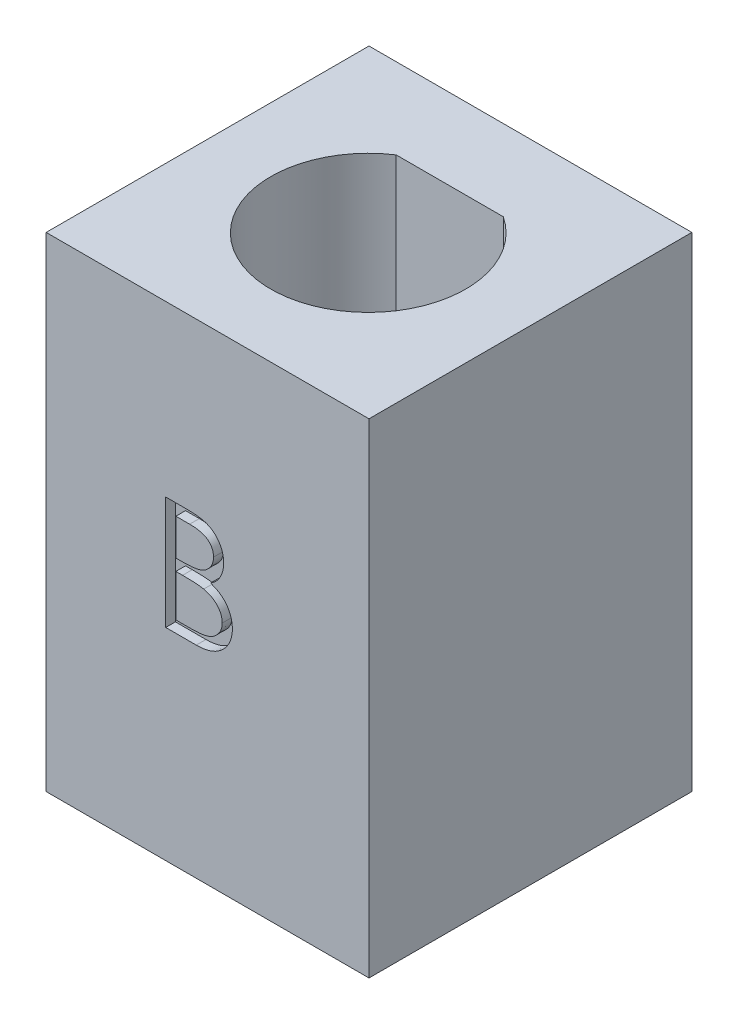
from build123d import *

# Parameters (mm, degrees)
SKETCH1_W           = 10
SKETCH1_H           = 10
BOSS_EXTRUDE1_DEPTH = 15
CUT_EXTRUDE1_DEPTH  = 0.3


with BuildPart() as part:
    # Sketch1 → Boss-Extrude1 (new body)
    with BuildSketch(Plane(origin=(0, 0, 0), x_dir=(1, 0, 0), z_dir=(0, 1, 0))):
        Rectangle(SKETCH1_W, SKETCH1_H)
        with BuildLine():
            Line((-1.658312395, 2.5), (1.658312395, 2.5))
            ThreePointArc((1.658312395, 2.5), (0, -3.043965134), (-1.658312395, 2.5))
        make_face(mode=Mode.SUBTRACT)
    extrude(amount=BOSS_EXTRUDE1_DEPTH)

    # Sketch2 → Cut-Extrude1 (cut)
    with BuildSketch(Plane.XY.offset(5)):
        with BuildLine():
            Line((-1.296362428, 9.754838654), (-0.6134698, 9.754838654))
            add(Edge.make_bspline(
                [(-0.6134698, 9.754838654), (-0.580041322, 9.754662904), (-0.515248611, 9.754322256), (-0.42102917, 9.749039125), (-0.332780359, 9.741835455), (-0.250476587, 9.730405362), (-0.174155884, 9.716613585), (-0.103588247, 9.699911769), (-0.038998075, 9.679885155), (0.038114662, 9.648038874), (0.126035323, 9.600715706), (0.221233715, 9.530787141), (0.302637955, 9.445254678), (0.372824272, 9.348772022), (0.428625391, 9.24263625), (0.468994689, 9.129377062), (0.494552564, 9.01045532), (0.497180998, 8.928812142), (0.498509367, 8.887550994)],
                knots=[0, 0, 0, 0, 0.00010027, 0.000194349, 0.000283026, 0.000365821, 0.000443519, 0.000515622, 0.000583254, 0.00064614, 0.000765662, 0.000881909, 0.000998927, 0.001118415, 0.001238844, 0.00135727, 0.001478274, 0.001601912, 0.001601912, 0.001601912, 0.001601912], degree=3))
            add(Edge.make_bspline(
                [(0.498509367, 8.887550994), (0.497416148, 8.848898438), (0.495267871, 8.772942521), (0.474725112, 8.661848412), (0.442564443, 8.556097193), (0.397859194, 8.456074808), (0.339757198, 8.364041195), (0.270898879, 8.279253929), (0.187822077, 8.205302872), (0.125578837, 8.163959969), (0.093962091, 8.142959648)],
                knots=[0, 0, 0, 0, 0.000115857, 0.00022767, 0.000337672, 0.000446877, 0.000555233, 0.000663318, 0.000773539, 0.000887324, 0.000887324, 0.000887324, 0.000887324], degree=3))
            add(Edge.make_bspline(
                [(0.093962091, 8.142959648), (0.133722519, 8.127694649), (0.209794066, 8.098488925), (0.314480078, 8.046853461), (0.404674923, 7.99069135), (0.481072069, 7.9293595), (0.546409724, 7.863250689), (0.603462666, 7.791395575), (0.65214404, 7.712856817), (0.693856964, 7.628453282), (0.72640572, 7.539046813), (0.750781624, 7.445476037), (0.764749073, 7.348076482), (0.766736714, 7.281791103), (0.767740136, 7.248328238)],
                knots=[0, 0, 0, 0, 0.000127722, 0.000244363, 0.000349599, 0.000445847, 0.000537565, 0.000627901, 0.000720503, 0.000814257, 0.000909859, 0.001005428, 0.001103887, 0.001204268, 0.001204268, 0.001204268, 0.001204268], degree=3))
            add(Edge.make_bspline(
                [(0.767740136, 7.248328238), (0.76676329, 7.214161366), (0.764841318, 7.146937088), (0.750661346, 7.048181953), (0.726652239, 6.953807006), (0.693581093, 6.863201824), (0.650418778, 6.776541689), (0.597890814, 6.693728425), (0.53525925, 6.615594095), (0.465196381, 6.541270471), (0.385934236, 6.474442684), (0.300418481, 6.414926977), (0.207572161, 6.365980915), (0.108920167, 6.324864894), (0.003355851, 6.293457695), (-0.108646757, 6.271485121), (-0.226991058, 6.256680084), (-0.308200809, 6.25546288), (-0.349848005, 6.254838654)],
                knots=[0, 0, 0, 0, 0.000102481, 0.000201635, 0.000298562, 0.000394165, 0.000490425, 0.000588455, 0.000687769, 0.000790423, 0.000894381, 0.000998232, 0.001102369, 0.001208616, 0.001318415, 0.001432129, 0.001550749, 0.00167562, 0.00167562, 0.00167562, 0.00167562], degree=3))
            Line((-0.349848005, 6.254838654), (-1.296362428, 6.254838654))
            Line((-1.296362428, 6.254838654), (-1.296362428, 9.754838654))
        make_face()
        with BuildLine():
            Line((-0.982259864, 9.395864295), (-0.982259864, 8.274069424))
            Line((-0.982259864, 8.274069424), (-0.771222204, 8.274069424))
            add(Edge.make_bspline(
                [(-0.771222204, 8.274069424), (-0.740373408, 8.274469347), (-0.680767249, 8.275242079), (-0.594447353, 8.277455596), (-0.514322334, 8.28365364), (-0.440530501, 8.289849902), (-0.373188057, 8.29992449), (-0.312444196, 8.311916612), (-0.257345599, 8.324599518), (-0.193806053, 8.346169004), (-0.121733105, 8.37804668), (-0.044900001, 8.427518516), (0.022834469, 8.486442869), (0.080031656, 8.554433831), (0.126843127, 8.629300017), (0.159356842, 8.709846897), (0.181404126, 8.794067029), (0.183395658, 8.851885282), (0.184406803, 8.881240898)],
                knots=[0, 0, 0, 0, 9.2559e-05, 0.000178842, 0.000258967, 0.000333616, 0.000400942, 0.000463093, 0.000519379, 0.000570374, 0.000664201, 0.000755025, 0.000843472, 0.000932526, 0.001020669, 0.001107124, 0.001192318, 0.001280185, 0.001280185, 0.001280185, 0.001280185], degree=3))
            add(Edge.make_bspline(
                [(0.184406803, 8.881240898), (0.183880622, 8.90066667), (0.182848462, 8.938772442), (0.17439516, 8.994321796), (0.160027585, 9.046565548), (0.141573292, 9.096219659), (0.115784603, 9.141731509), (0.08542114, 9.184674705), (0.04873545, 9.223586823), (0.006978137, 9.259956321), (-0.041030486, 9.292200849), (-0.095261777, 9.320441612), (-0.156449455, 9.343182389), (-0.223562309, 9.363098541), (-0.297633397, 9.377086835), (-0.37780795, 9.388740223), (-0.464742669, 9.394672965), (-0.524887772, 9.395458328), (-0.555977813, 9.395864295)],
                knots=[0, 0, 0, 0, 5.8261e-05, 0.000114285, 0.000168029, 0.000220632, 0.000272728, 0.000324483, 0.000378062, 0.000432741, 0.000490301, 0.000551137, 0.000615721, 0.000685833, 0.000760908, 0.00084162, 0.000928788, 0.00102206, 0.00102206, 0.00102206, 0.00102206], degree=3))
            Line((-0.555977813, 9.395864295), (-0.982259864, 9.395864295))
        make_face(mode=Mode.SUBTRACT)
        with BuildLine():
            Line((-0.982259864, 7.915095065), (-0.982259864, 6.613813013))
            Line((-0.982259864, 6.613813013), (-0.534944159, 6.613813013))
            add(Edge.make_bspline(
                [(-0.534944159, 6.613813013), (-0.502925233, 6.614196761), (-0.441212974, 6.614936383), (-0.352111744, 6.617350938), (-0.269528641, 6.622843214), (-0.193840505, 6.631489063), (-0.124230052, 6.640867512), (-0.061532349, 6.653478793), (-0.005239156, 6.667927754), (0.060035152, 6.690261926), (0.13353866, 6.724958397), (0.212749517, 6.777272623), (0.283175735, 6.839595931), (0.342980994, 6.911726845), (0.391993983, 6.990158172), (0.427649438, 7.073303522), (0.449640294, 7.15978905), (0.452302464, 7.218755762), (0.453637572, 7.248328238)],
                knots=[0, 0, 0, 0, 9.6064e-05, 0.000185151, 0.000267373, 0.000344257, 0.000413665, 0.000478015, 0.000536005, 0.000587888, 0.000684801, 0.000778918, 0.000871787, 0.000965866, 0.001059062, 0.00114827, 0.001236355, 0.001324974, 0.001324974, 0.001324974, 0.001324974], degree=3))
            add(Edge.make_bspline(
                [(0.453637572, 7.248328238), (0.453361467, 7.266821578), (0.452813712, 7.30350996), (0.444553097, 7.357425779), (0.432539228, 7.409651653), (0.417007794, 7.460329393), (0.394388327, 7.508542769), (0.367981782, 7.555245329), (0.33702038, 7.600498808), (0.288776214, 7.657711062), (0.21860423, 7.723628075), (0.118897454, 7.788165577), (0.005525156, 7.840213384), (-0.076702337, 7.86231286), (-0.119178935, 7.873728879)],
                knots=[0, 0, 0, 0, 5.5429e-05, 0.000109963, 0.000163198, 0.000216191, 0.000268588, 0.000322593, 0.000377046, 0.000432793, 0.000546889, 0.000664343, 0.000787646, 0.000919405, 0.000919405, 0.000919405, 0.000919405], degree=3))
            add(Edge.make_bspline(
                [(-0.119178935, 7.873728879), (-0.13620803, 7.877183963), (-0.173130623, 7.884675297), (-0.233338203, 7.892583001), (-0.302074072, 7.899628061), (-0.379496949, 7.904839218), (-0.46570479, 7.910225762), (-0.560881709, 7.912320583), (-0.664639024, 7.914819843), (-0.736631396, 7.915000977), (-0.774026691, 7.915095065)],
                knots=[0, 0, 0, 0, 5.2115e-05, 0.000112995, 0.000182062, 0.000259389, 0.000345767, 0.00044116, 0.000544948, 0.000657129, 0.000657129, 0.000657129, 0.000657129], degree=3))
            Line((-0.774026691, 7.915095065), (-0.982259864, 7.915095065))
        make_face(mode=Mode.SUBTRACT)
    extrude(amount=-CUT_EXTRUDE1_DEPTH, mode=Mode.SUBTRACT)


solid = part.part
